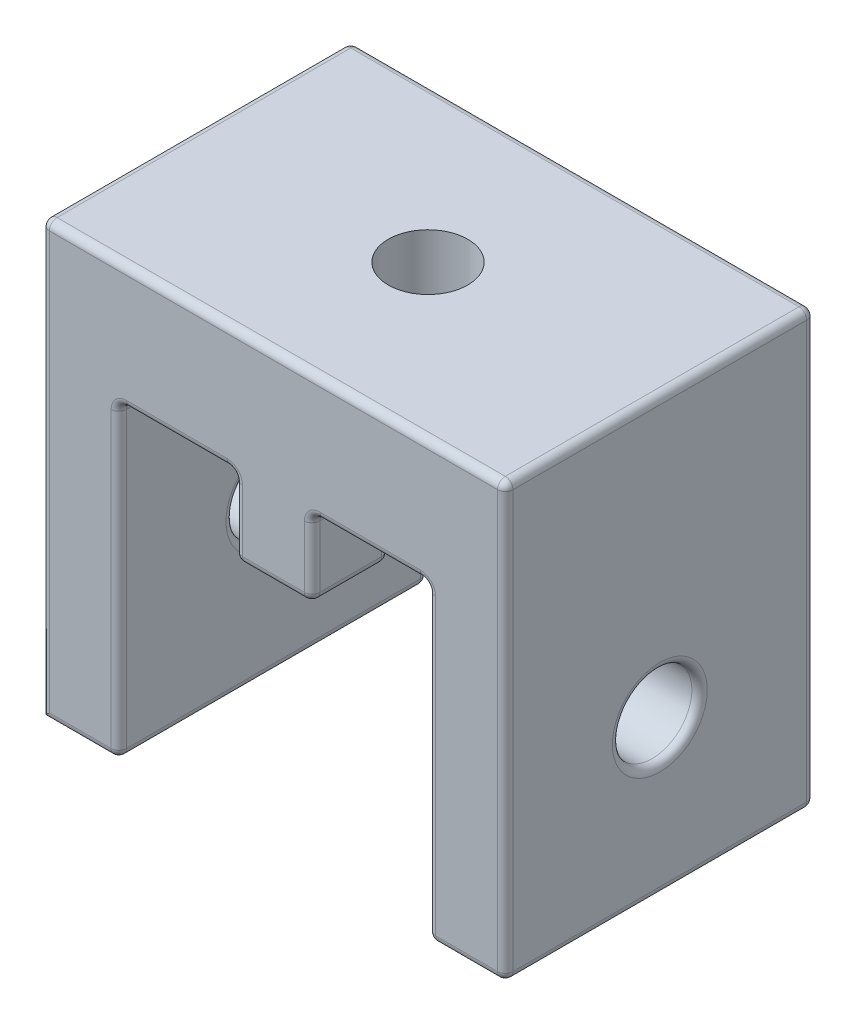
from build123d import *

# Parameters (mm, degrees)
BOSS_EXTRUDE1_DEPTH              = 25.4
SKETCH2_W                        = 6.35
SKETCH2_H                        = 6.35
BOSS_EXTRUDE2_DEPTH              = 6.35
F_97_0_0059_DIAMETER_HOLE3_D     = 6.5278
F_97_0_0059_DIAMETER_HOLE1_D     = 6.5278
F_97_0_0059_DIAMETER_HOLE1_DEPTH = 6.35
F_97_0_0059_DIAMETER_HOLE2_D     = 6.5278
BOSS_EXTRUDE3_DEPTH              = 5.08
FILLET1_R                        = 0.635


with BuildPart() as part:
    # Sketch1 → Boss-Extrude1 (new body)
    with BuildSketch(Plane.XY):
        Polygon((0, 0), (6.35, 0), (6.35, 25.4), (31.75, 25.4), (31.75, 0), (38.1, 0), (38.1, 35.56), (0, 35.56), align=None)
    extrude(amount=BOSS_EXTRUDE1_DEPTH)

    # Sketch2 → Boss-Extrude2 (add)
    with BuildSketch(Plane.XZ.offset(-25.4)):
        with Locations((19.05, 3.175)):
            Rectangle(SKETCH2_W, SKETCH2_H)
    boss_extrude2 = extrude(amount=BOSS_EXTRUDE2_DEPTH)

    # Mirror1: Boss-Extrude2 across plane
    add(boss_extrude2.mirror(Plane.XY.offset(12.7)))

    # #97 (0.0059) Diameter Hole3 (through all)
    with Locations(Plane(origin=(0, 35.56, 0), x_dir=(-1, 0, 0), z_dir=(0, 1, 0))):
        with Locations((-19.05, 12.7)):
            Hole(F_97_0_0059_DIAMETER_HOLE3_D / 2)

    # #97 (0.0059) Diameter Hole1
    with Locations(Plane(origin=(6.35, 0, 0), x_dir=(0, 0, -1), z_dir=(1, 0, 0))):
        with Locations((-12.7, 12.7)):
            Hole(F_97_0_0059_DIAMETER_HOLE1_D / 2, depth=F_97_0_0059_DIAMETER_HOLE1_DEPTH)

    # #97 (0.0059) Diameter Hole2 (through all)
    with Locations(Plane.ZY.offset(-31.75)):
        with Locations((12.7, 12.7)):
            Hole(F_97_0_0059_DIAMETER_HOLE2_D / 2)


with BuildPart() as body_2:
    # Sketch9 → Boss-Extrude3 (new body)
    with BuildSketch(Plane(origin=(0, 25.4, 0), x_dir=(-1, 0, 0), z_dir=(0, 1, 0))):
        Polygon((-25.35581964, 12.7), (-22.20290982, 7.239), (-15.89709018, 7.239), (-12.74418036, 12.7), (-15.89709018, 18.161), (-22.20290982, 18.161), align=None)
    extrude(amount=BOSS_EXTRUDE3_DEPTH)


with BuildPart() as part_1:
    add(part.part)

    # Combine1: cut body 2
    add(body_2.part, mode=Mode.SUBTRACT)

    # Fillet1
    fillet1_edges = [part_1.edges().sort_by_distance(p)[0] for p in [
        (6.35, 12.7, 25.4),
        (3.175, 0, 0),
        (0, 17.78, 0),
        (11.1125, 25.4, 25.4),
        (0, 35.56, 12.7),
        (38.1, 35.56, 12.7),
        (38.1, 0, 12.7),
        (31.75, 0, 12.7),
        (31.75, 25.4, 12.7),
        (6.35, 25.4, 12.7),
        (6.35, 0, 12.7),
        (31.75, 12.7, 25.4),
        (34.925, 0, 25.4),
        (38.1, 17.78, 25.4),
        (26.9875, 25.4, 0),
        (19.05, 35.56, 25.4),
        (15.875, 25.4, 3.175),
        (15.875, 22.225, 6.35),
        (15.875, 22.225, 0),
        (22.225, 25.4, 3.175),
        (22.225, 22.225, 0),
        (19.05, 25.4, 6.35),
        (22.225, 22.225, 6.35),
        (15.875, 19.05, 3.175),
        (19.05, 19.05, 0),
        (22.225, 19.05, 3.175),
        (19.05, 19.05, 6.35),
        (26.9875, 25.4, 25.4),
        (15.875, 19.05, 22.225),
        (15.875, 22.225, 25.4),
        (19.05, 19.05, 19.05),
        (15.875, 22.225, 19.05),
        (22.225, 19.05, 22.225),
        (22.225, 22.225, 19.05),
        (19.05, 19.05, 25.4),
        (22.225, 22.225, 25.4),
        (15.875, 25.4, 22.225),
        (0, 17.78, 25.4),
        (22.225, 25.4, 22.225),
        (19.05, 25.4, 19.05),
        (6.35, 12.7, 9.4361),
        (0, 12.7, 9.4361),
        (31.75, 12.7, 15.9639),
        (38.1, 12.7, 15.9639),
        (3.175, 0, 25.4),
        (19.05, 35.56, 0),
        (38.1, 17.78, 0),
        (34.925, 0, 0),
        (31.75, 12.7, 0),
        (11.1125, 25.4, 0),
        (6.35, 12.7, 0),
    ]]
    fillet(fillet1_edges, radius=FILLET1_R)


solid = part_1.part
